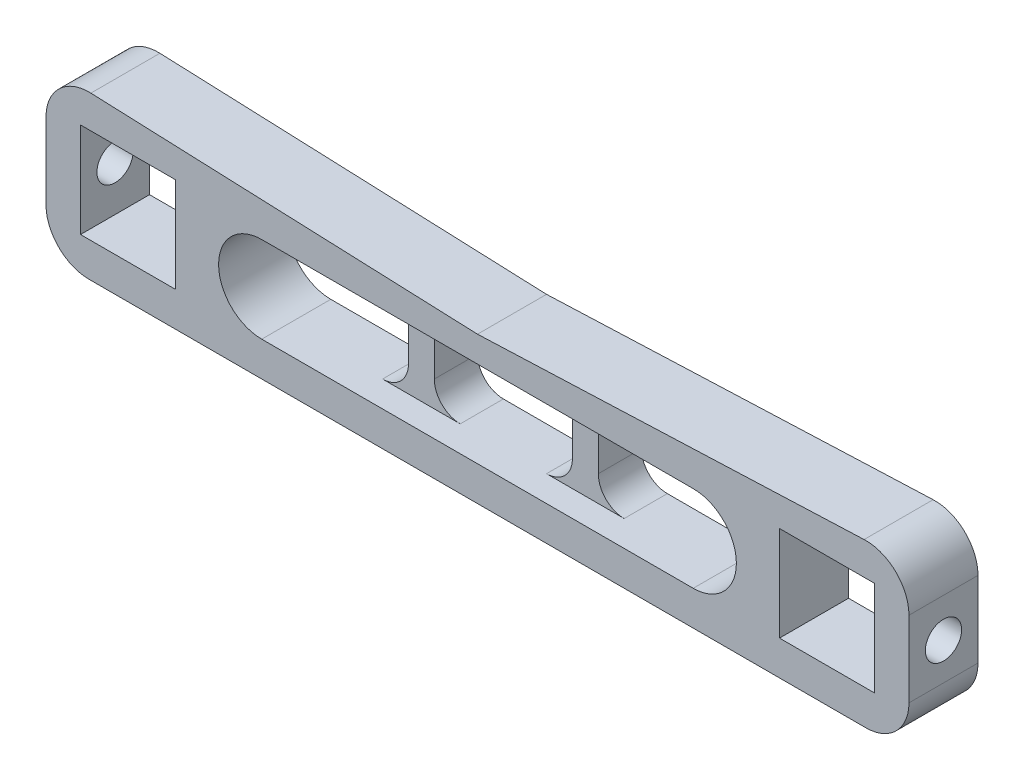
from build123d import *

# Parameters (mm, degrees)
SKETCH1_W                       = 11
SKETCH1_H                       = 11
BOSS_EXTRUDE1_DEPTH             = 8
BOSS_EXTRUDE2_REACH             = 16
SKETCH2_W                       = 3
SKETCH2_H                       = 5
FILLET1_R                       = 3
M5_TAPPED_HOLE1_D               = 4.2
M5_TAPPED_HOLE1_DEPTH           = 4
M5_TAPPED_HOLE1_ON_FACE_2_D     = 4.2
M5_TAPPED_HOLE1_ON_FACE_2_DEPTH = 4


with BuildPart() as part:
    # Sketch1 → Boss-Extrude1 (new body)
    with BuildSketch(Plane.XY):
        with BuildLine():
            Line((50, -5.203998401), (50, -14))
            ThreePointArc((50, -14), (48.535533906, -17.535533906), (45, -19))
            Line((45, -19), (-45, -19))
            ThreePointArc((-45, -19), (-48.535533906, -17.535533906), (-50, -14))
            Line((-50, -14), (-50, -5.203998401))
            ThreePointArc((-50, -5.203998401), (-48.46415928, -1.59850253), (-44.800159808, -0.207993608))
            Line((-44.800159808, -0.207993608), (0, -2))
            Line((0, -2), (44.800159808, -0.207993608))
            ThreePointArc((44.800159808, -0.207993608), (48.46415928, -1.59850253), (50, -5.203998401))
        make_face()
        with Locations((-40.5, -9.5)):
            Rectangle(SKETCH1_W, SKETCH1_H, mode=Mode.SUBTRACT)
        with Locations((40.5, -9.5)):
            Rectangle(SKETCH1_W, SKETCH1_H, mode=Mode.SUBTRACT)
        with BuildLine():
            Line((-25, -5), (25, -5))
            ThreePointArc((25, -5), (30, -10), (25, -15))
            Line((25, -15), (-25, -15))
            ThreePointArc((-25, -15), (-30, -10), (-25, -5))
        make_face(mode=Mode.SUBTRACT)
    extrude(amount=BOSS_EXTRUDE1_DEPTH)

    # Sketch2 → Boss-Extrude2 (add, up to next)
    with BuildSketch(Plane.XZ.offset(5), mode=Mode.PRIVATE) as boss_extrude2_sk1:
        with Locations((-9.5, 2.5)):
            Rectangle(SKETCH2_W, SKETCH2_H)
    boss_extrude2_tool1 = extrude(boss_extrude2_sk1.sketch, amount=BOSS_EXTRUDE2_REACH, mode=Mode.PRIVATE) - part.part
    add(boss_extrude2_tool1.solids().sort_by_distance((-9.5, -5, 2.5))[0])
    # Sketch2 → Boss-Extrude2 (add, up to next)
    with BuildSketch(Plane.XZ.offset(5), mode=Mode.PRIVATE) as boss_extrude2_sk2:
        with Locations((9.5, 2.5)):
            Rectangle(SKETCH2_W, SKETCH2_H)
    boss_extrude2_tool2 = extrude(boss_extrude2_sk2.sketch, amount=BOSS_EXTRUDE2_REACH, mode=Mode.PRIVATE) - part.part
    add(boss_extrude2_tool2.solids().sort_by_distance((9.5, -5, 2.5))[0])

    # Fillet1
    fillet1_edges = [part.edges().sort_by_distance(p)[0] for p in [
        (-8, -15, 2.5),
        (-8, -5, 2.5),
        (-11, -15, 2.5),
        (-11, -5, 2.5),
        (11, -15, 2.5),
        (11, -5, 2.5),
        (8, -15, 2.5),
        (8, -5, 2.5),
    ]]
    fillet(fillet1_edges, radius=FILLET1_R)

    # M5 Tapped Hole1
    with Locations(Plane(origin=(-50, -9.703998401, 4), x_dir=(0, 0, -1), z_dir=(-1, 0, 0))):
        with Locations((0, 0)):
            Hole(M5_TAPPED_HOLE1_D / 2, depth=M5_TAPPED_HOLE1_DEPTH)

    # M5 Tapped Hole1 on face 2
    with Locations(Plane(origin=(50, -9.703998401, 4), x_dir=(0, 0, 1), z_dir=(1, 0, 0))):
        with Locations((0, 0)):
            Hole(M5_TAPPED_HOLE1_ON_FACE_2_D / 2, depth=M5_TAPPED_HOLE1_ON_FACE_2_DEPTH)


solid = part.part
